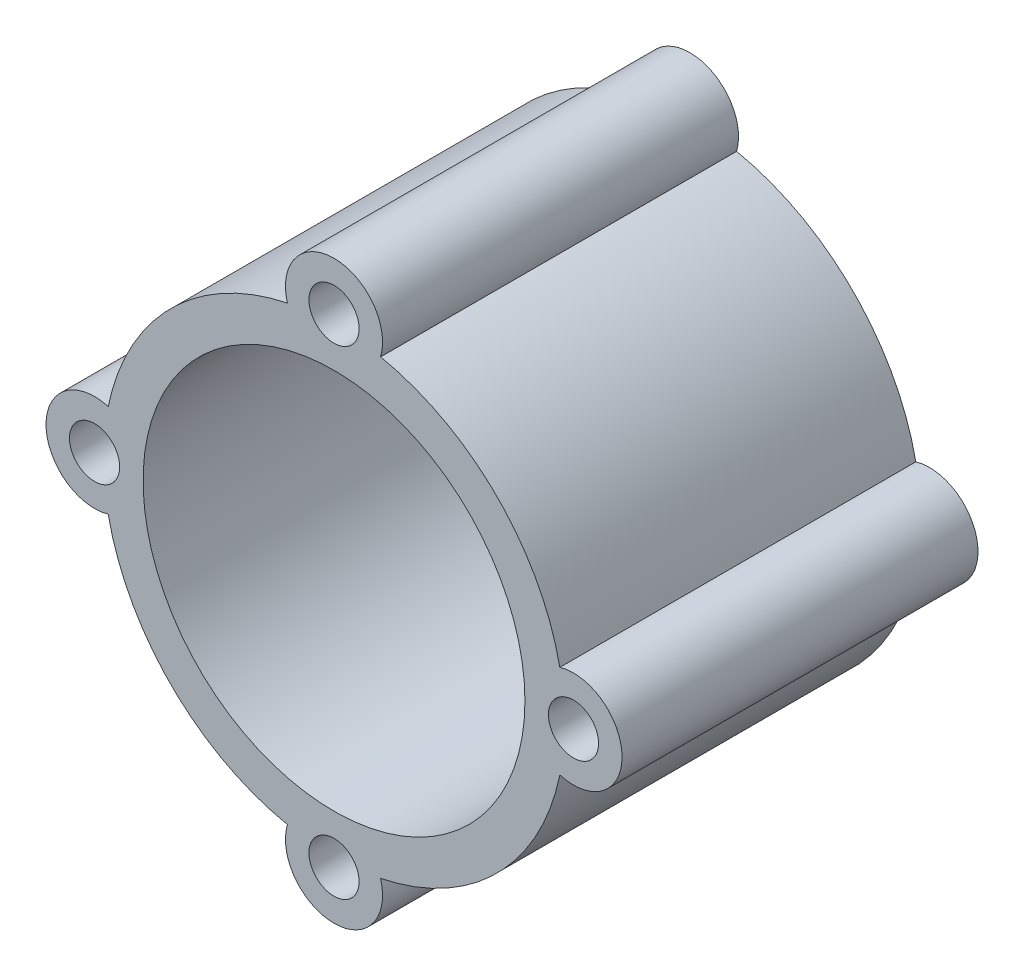
from build123d import *

# Parameters (mm, degrees)
SKETCH1_R           = 28.5
SKETCH1_R_2         = 23.6
BOSS_EXTRUDE1_DEPTH = 44
SKETCH2_R           = 6
BOSS_EXTRUDE2_DEPTH = 44
SKETCH3_R           = 3.1
CUT_EXTRUDE1_DEPTH  = 45


with BuildPart() as part:
    # Sketch1 → Boss-Extrude1 (new body)
    with BuildSketch(Plane.XY):
        Circle(SKETCH1_R)
        Circle(SKETCH1_R_2, mode=Mode.SUBTRACT)
    extrude(amount=BOSS_EXTRUDE1_DEPTH)

    # Sketch2 → Boss-Extrude2 (add)
    with BuildSketch(Plane(origin=(0, 0, 0), x_dir=(-1, 0, 0), z_dir=(0, 0, -1))):
        with Locations((0, 29.6)):
            Circle(SKETCH2_R)
        with Locations((29.6, 0)):
            Circle(SKETCH2_R)
        with Locations((0, -29.6)):
            Circle(SKETCH2_R)
        with Locations((-29.6, 0)):
            Circle(SKETCH2_R)
    extrude(amount=-BOSS_EXTRUDE2_DEPTH)

    # Sketch3 → Cut-Extrude1 (cut, through all)
    with BuildSketch(Plane(origin=(0, 0, 0), x_dir=(-1, 0, 0), z_dir=(0, 0, -1))):
        with Locations((0, 29.6)):
            Circle(SKETCH3_R)
        with Locations((29.6, 0)):
            Circle(SKETCH3_R)
        with Locations((-29.6, 0)):
            Circle(SKETCH3_R)
        with Locations((0, -29.6)):
            Circle(SKETCH3_R)
    extrude(amount=-CUT_EXTRUDE1_DEPTH, mode=Mode.SUBTRACT)


solid = part.part
